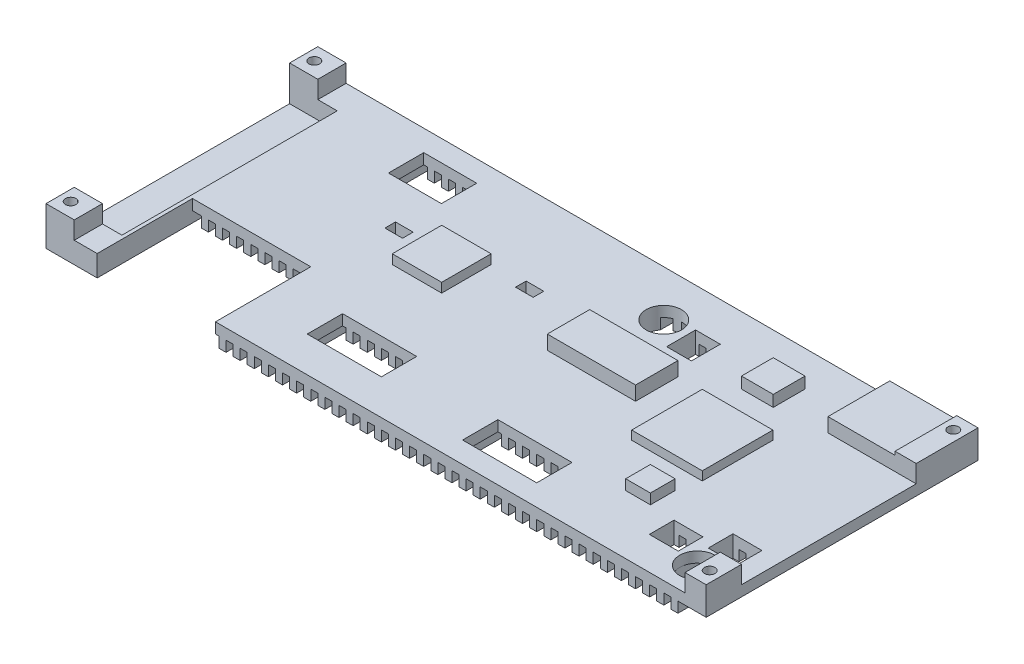
from build123d import *

# Parameters (mm, degrees)
SKETCH_1_W           = 187
SKETCH_1_H           = 77
EXTRUDE_1_DEPTH      = 6
SKETCH_5_R           = 5
SKETCH_5_W           = 21
SKETCH_5_H           = 10
SKETCH_5_W_2         = 15
SKETCH_5_W_3         = 5
SKETCH_5_H_2         = 3
SKETCH_5_W_4         = 33.5
SKETCH_5_H_3         = 27
CUT_EXTRUDE_2_DEPTH  = 7
SKETCH_7_OUTSIDE_W   = 229.464
SKETCH_7_OUTSIDE_H   = 119.464
SKETCH_7_OUTSIDE_W_2 = 2
SKETCH_7_OUTSIDE_H_2 = 77
SKETCH_7_OUTSIDE_H_3 = 50
CUT_EXTRUDE_13_DEPTH = 3
SKETCH_9_W           = 25
SKETCH_9_H           = 17.5
SKETCH_9_H_2         = 12
EXTRUDE_3_DEPTH      = 4
SKETCH_10_W          = 6
SKETCH_10_H          = 17.5
EXTRUDE_7_DEPTH      = 1
SKETCH_16_R          = 1.5
CUT_EXTRUDE_15_DEPTH = 12
SKETCH_17_W          = 6
SKETCH_17_H          = 10
EXTRUDE_8_DEPTH      = 5
SKETCH_18_R          = 1.5
CUT_EXTRUDE_16_DEPTH = 12
SKETCH_20_W          = 20
SKETCH_20_H          = 20
EXTRUDE_9_DEPTH      = 2.5
SKETCH_21_W          = 8.2
SKETCH_21_H          = 7
SKETCH_21_W_2        = 7
SKETCH_21_H_2        = 8.2
CUT_EXTRUDE_17_DEPTH = 7
SKETCH_22_W          = 9
SKETCH_22_H          = 9
EXTRUDE_10_DEPTH     = 3.2
SKETCH_24_W          = 14
SKETCH_24_H          = 14
EXTRUDE_12_DEPTH     = 2.65
SKETCH_23_W          = 7
SKETCH_23_H          = 7
EXTRUDE_11_DEPTH     = 2.9
SKETCH_25_W          = 14.5
SKETCH_25_H          = 77
EXTRUDE_13_DEPTH     = 3
SKETCH_26_W          = 13.5
SKETCH_26_H          = 61
CUT_EXTRUDE_19_DEPTH = 5
SKETCH_27_W          = 8
SKETCH_27_H          = 8
EXTRUDE_14_DEPTH     = 5
SKETCH_28_R          = 1.5
CUT_EXTRUDE_20_DEPTH = 12
SKETCH_29_R          = 1.5
CUT_EXTRUDE_21_DEPTH = 12


with BuildPart() as part:
    # Эскиз1 → Бобышка-Вытянуть1 (new body)
    with BuildSketch(Plane(origin=(0, 0, 0), x_dir=(1, 0, 0), z_dir=(0, 1, 0))):
        with Locations((93.5, 38.5)):
            Rectangle(SKETCH_1_W, SKETCH_1_H)
    extrude(amount=EXTRUDE_1_DEPTH)

    # Эскиз5 → Вырез-Вытянуть2 (cut, through all)
    with BuildSketch(Plane(origin=(0, 6, 0), x_dir=(1, 0, 0), z_dir=(0, 1, 0))):
        with Locations((111, 64)):
            Circle(SKETCH_5_R)
        with Locations((176, 8.5)):
            Circle(SKETCH_5_R)
        with Locations((122.5, 11)):
            Rectangle(SKETCH_5_W, SKETCH_5_H)
        with Locations((43.5, 66)):
            Rectangle(SKETCH_5_W_2, SKETCH_5_H)
        with Locations((74.5, 15)):
            Rectangle(SKETCH_5_W, SKETCH_5_H)
        with Locations((84.5, 52.5)):
            Rectangle(SKETCH_5_W_3, SKETCH_5_H_2)
        with Locations((51.5, 48.5)):
            Rectangle(SKETCH_5_W_3, SKETCH_5_H_2)
        with Locations((31.25, 13.5)):
            Rectangle(SKETCH_5_W_4, SKETCH_5_H_3)
    extrude(amount=-CUT_EXTRUDE_2_DEPTH, mode=Mode.SUBTRACT)

    # Эскиз7 outside → Вырез-Вытянуть13 (cut)
    with BuildSketch(Plane.XZ):
        with Locations((93.5, -38.5)):
            Rectangle(SKETCH_7_OUTSIDE_W, SKETCH_7_OUTSIDE_H)
        with Locations((174, -38.5)):
            Rectangle(SKETCH_7_OUTSIDE_W_2, SKETCH_7_OUTSIDE_H_2, mode=Mode.SUBTRACT)
        with Locations((170, -38.5)):
            Rectangle(SKETCH_7_OUTSIDE_W_2, SKETCH_7_OUTSIDE_H_2, mode=Mode.SUBTRACT)
        with Locations((162, -38.5)):
            Rectangle(SKETCH_7_OUTSIDE_W_2, SKETCH_7_OUTSIDE_H_2, mode=Mode.SUBTRACT)
        with Locations((154, -38.5)):
            Rectangle(SKETCH_7_OUTSIDE_W_2, SKETCH_7_OUTSIDE_H_2, mode=Mode.SUBTRACT)
        with Locations((158, -38.5)):
            Rectangle(SKETCH_7_OUTSIDE_W_2, SKETCH_7_OUTSIDE_H_2, mode=Mode.SUBTRACT)
        with Locations((150, -38.5)):
            Rectangle(SKETCH_7_OUTSIDE_W_2, SKETCH_7_OUTSIDE_H_2, mode=Mode.SUBTRACT)
        with Locations((146, -38.5)):
            Rectangle(SKETCH_7_OUTSIDE_W_2, SKETCH_7_OUTSIDE_H_2, mode=Mode.SUBTRACT)
        with Locations((138, -38.5)):
            Rectangle(SKETCH_7_OUTSIDE_W_2, SKETCH_7_OUTSIDE_H_2, mode=Mode.SUBTRACT)
        with Locations((142, -38.5)):
            Rectangle(SKETCH_7_OUTSIDE_W_2, SKETCH_7_OUTSIDE_H_2, mode=Mode.SUBTRACT)
        with Locations((166, -38.5)):
            Rectangle(SKETCH_7_OUTSIDE_W_2, SKETCH_7_OUTSIDE_H_2, mode=Mode.SUBTRACT)
        with Locations((134, -38.5)):
            Rectangle(SKETCH_7_OUTSIDE_W_2, SKETCH_7_OUTSIDE_H_2, mode=Mode.SUBTRACT)
        with Locations((130, -38.5)):
            Rectangle(SKETCH_7_OUTSIDE_W_2, SKETCH_7_OUTSIDE_H_2, mode=Mode.SUBTRACT)
        with Locations((126, -38.5)):
            Rectangle(SKETCH_7_OUTSIDE_W_2, SKETCH_7_OUTSIDE_H_2, mode=Mode.SUBTRACT)
        with Locations((118, -38.5)):
            Rectangle(SKETCH_7_OUTSIDE_W_2, SKETCH_7_OUTSIDE_H_2, mode=Mode.SUBTRACT)
        with Locations((122, -38.5)):
            Rectangle(SKETCH_7_OUTSIDE_W_2, SKETCH_7_OUTSIDE_H_2, mode=Mode.SUBTRACT)
        with Locations((114, -38.5)):
            Rectangle(SKETCH_7_OUTSIDE_W_2, SKETCH_7_OUTSIDE_H_2, mode=Mode.SUBTRACT)
        with Locations((110, -38.5)):
            Rectangle(SKETCH_7_OUTSIDE_W_2, SKETCH_7_OUTSIDE_H_2, mode=Mode.SUBTRACT)
        with Locations((106, -38.5)):
            Rectangle(SKETCH_7_OUTSIDE_W_2, SKETCH_7_OUTSIDE_H_2, mode=Mode.SUBTRACT)
        with Locations((102, -38.5)):
            Rectangle(SKETCH_7_OUTSIDE_W_2, SKETCH_7_OUTSIDE_H_2, mode=Mode.SUBTRACT)
        with Locations((98, -38.5)):
            Rectangle(SKETCH_7_OUTSIDE_W_2, SKETCH_7_OUTSIDE_H_2, mode=Mode.SUBTRACT)
        with Locations((94, -38.5)):
            Rectangle(SKETCH_7_OUTSIDE_W_2, SKETCH_7_OUTSIDE_H_2, mode=Mode.SUBTRACT)
        with Locations((178, -38.5)):
            Rectangle(SKETCH_7_OUTSIDE_W_2, SKETCH_7_OUTSIDE_H_2, mode=Mode.SUBTRACT)
        with Locations((90, -38.5)):
            Rectangle(SKETCH_7_OUTSIDE_W_2, SKETCH_7_OUTSIDE_H_2, mode=Mode.SUBTRACT)
        with Locations((86, -38.5)):
            Rectangle(SKETCH_7_OUTSIDE_W_2, SKETCH_7_OUTSIDE_H_2, mode=Mode.SUBTRACT)
        with Locations((82, -38.5)):
            Rectangle(SKETCH_7_OUTSIDE_W_2, SKETCH_7_OUTSIDE_H_2, mode=Mode.SUBTRACT)
        with Locations((78, -38.5)):
            Rectangle(SKETCH_7_OUTSIDE_W_2, SKETCH_7_OUTSIDE_H_2, mode=Mode.SUBTRACT)
        with Locations((74, -38.5)):
            Rectangle(SKETCH_7_OUTSIDE_W_2, SKETCH_7_OUTSIDE_H_2, mode=Mode.SUBTRACT)
        with Locations((70, -38.5)):
            Rectangle(SKETCH_7_OUTSIDE_W_2, SKETCH_7_OUTSIDE_H_2, mode=Mode.SUBTRACT)
        with Locations((62, -38.5)):
            Rectangle(SKETCH_7_OUTSIDE_W_2, SKETCH_7_OUTSIDE_H_2, mode=Mode.SUBTRACT)
        with Locations((66, -38.5)):
            Rectangle(SKETCH_7_OUTSIDE_W_2, SKETCH_7_OUTSIDE_H_2, mode=Mode.SUBTRACT)
        with Locations((58, -38.5)):
            Rectangle(SKETCH_7_OUTSIDE_W_2, SKETCH_7_OUTSIDE_H_2, mode=Mode.SUBTRACT)
        with Locations((54, -38.5)):
            Rectangle(SKETCH_7_OUTSIDE_W_2, SKETCH_7_OUTSIDE_H_2, mode=Mode.SUBTRACT)
        with Locations((50, -38.5)):
            Rectangle(SKETCH_7_OUTSIDE_W_2, SKETCH_7_OUTSIDE_H_2, mode=Mode.SUBTRACT)
        with Locations((46, -52)):
            Rectangle(SKETCH_7_OUTSIDE_W_2, SKETCH_7_OUTSIDE_H_3, mode=Mode.SUBTRACT)
        with Locations((42, -52)):
            Rectangle(SKETCH_7_OUTSIDE_W_2, SKETCH_7_OUTSIDE_H_3, mode=Mode.SUBTRACT)
        with Locations((38, -52)):
            Rectangle(SKETCH_7_OUTSIDE_W_2, SKETCH_7_OUTSIDE_H_3, mode=Mode.SUBTRACT)
        with Locations((34, -52)):
            Rectangle(SKETCH_7_OUTSIDE_W_2, SKETCH_7_OUTSIDE_H_3, mode=Mode.SUBTRACT)
        with Locations((30, -52)):
            Rectangle(SKETCH_7_OUTSIDE_W_2, SKETCH_7_OUTSIDE_H_3, mode=Mode.SUBTRACT)
        with Locations((26, -52)):
            Rectangle(SKETCH_7_OUTSIDE_W_2, SKETCH_7_OUTSIDE_H_3, mode=Mode.SUBTRACT)
        with Locations((22, -52)):
            Rectangle(SKETCH_7_OUTSIDE_W_2, SKETCH_7_OUTSIDE_H_3, mode=Mode.SUBTRACT)
        with Locations((18, -52)):
            Rectangle(SKETCH_7_OUTSIDE_W_2, SKETCH_7_OUTSIDE_H_3, mode=Mode.SUBTRACT)
    extrude(amount=-CUT_EXTRUDE_13_DEPTH, mode=Mode.SUBTRACT)

    # Эскиз9 → Бобышка-Вытянуть3 (add)
    with BuildSketch(Plane(origin=(0, 6, 0), x_dir=(1, 0, 0), z_dir=(0, 1, 0))):
        with Locations((174.5, 68.25)):
            Rectangle(SKETCH_9_W, SKETCH_9_H)
        with Locations((114.5, 46)):
            Rectangle(SKETCH_9_W, SKETCH_9_H_2)
    extrude(amount=EXTRUDE_3_DEPTH)

    # Эскиз10 → Бобышка-Вытянуть7 (add)
    with BuildSketch(Plane(origin=(0, 10, 0), x_dir=(1, 0, 0), z_dir=(0, 1, 0))):
        with Locations((184, 68.25)):
            Rectangle(SKETCH_10_W, SKETCH_10_H)
    extrude(amount=EXTRUDE_7_DEPTH)

    # Эскиз16 → Вырез-Вытянуть15 (cut, through all)
    with BuildSketch(Plane(origin=(0, 11, 0), x_dir=(1, 0, 0), z_dir=(0, 1, 0))):
        with Locations((184, 73)):
            Circle(SKETCH_16_R)
    extrude(amount=-CUT_EXTRUDE_15_DEPTH, mode=Mode.SUBTRACT)

    # Эскиз17 → Бобышка-Вытянуть8 (add)
    with BuildSketch(Plane(origin=(0, 6, 0), x_dir=(1, 0, 0), z_dir=(0, 1, 0))):
        with Locations((184, 5)):
            Rectangle(SKETCH_17_W, SKETCH_17_H)
    extrude(amount=EXTRUDE_8_DEPTH)

    # Эскиз18 → Вырез-Вытянуть16 (cut, through all)
    with BuildSketch(Plane(origin=(0, 11, 0), x_dir=(1, 0, 0), z_dir=(0, 1, 0))):
        with Locations((184, 4)):
            Circle(SKETCH_18_R)
    extrude(amount=-CUT_EXTRUDE_16_DEPTH, mode=Mode.SUBTRACT)

    # Эскиз20 → Бобышка-Вытянуть9 (add)
    with BuildSketch(Plane(origin=(0, 6, 0), x_dir=(1, 0, 0), z_dir=(0, 1, 0))):
        with Locations((146, 39.9)):
            Rectangle(SKETCH_20_W, SKETCH_20_H)
    extrude(amount=EXTRUDE_9_DEPTH)

    # Эскиз21 → Вырез-Вытянуть17 (cut, through all)
    with BuildSketch(Plane(origin=(0, 6, 0), x_dir=(1, 0, 0), z_dir=(0, 1, 0))):
        with Locations((177.4, 17.8)):
            Rectangle(SKETCH_21_W, SKETCH_21_H)
        with Locations((165.7, 12.8)):
            Rectangle(SKETCH_21_W, SKETCH_21_H)
        with Locations((121.5, 61.9)):
            Rectangle(SKETCH_21_W_2, SKETCH_21_H_2)
    extrude(amount=-CUT_EXTRUDE_17_DEPTH, mode=Mode.SUBTRACT)

    # Эскиз22 → Бобышка-Вытянуть10 (add)
    with BuildSketch(Plane(origin=(0, 6, 0), x_dir=(1, 0, 0), z_dir=(0, 1, 0))):
        with Locations((143.5, 62.5)):
            Rectangle(SKETCH_22_W, SKETCH_22_H)
    extrude(amount=EXTRUDE_10_DEPTH)

    # Эскиз24 → Бобышка-Вытянуть12 (add)
    with BuildSketch(Plane(origin=(0, 6, 0), x_dir=(1, 0, 0), z_dir=(0, 1, 0))):
        with Locations((66, 46.083478514)):
            Rectangle(SKETCH_24_W, SKETCH_24_H)
    extrude(amount=EXTRUDE_12_DEPTH)

    # Эскиз23 → Бобышка-Вытянуть11 (add)
    with BuildSketch(Plane(origin=(0, 6, 0), x_dir=(1, 0, 0), z_dir=(0, 1, 0))):
        with Locations((151, 20.2)):
            Rectangle(SKETCH_23_W, SKETCH_23_H)
    extrude(amount=EXTRUDE_11_DEPTH)

    # Эскиз25 → Бобышка-Вытянуть13 (add)
    with BuildSketch(Plane.XZ.offset(-3)):
        with Locations((7.25, -38.5)):
            Rectangle(SKETCH_25_W, SKETCH_25_H)
    extrude(amount=EXTRUDE_13_DEPTH)

    # Эскиз26 → Вырез-Вытянуть19 (cut)
    with BuildSketch(Plane(origin=(0, 6, 0), x_dir=(1, 0, 0), z_dir=(0, 1, 0))):
        with Locations((6.75, 38.5)):
            Rectangle(SKETCH_26_W, SKETCH_26_H)
    extrude(amount=-CUT_EXTRUDE_19_DEPTH, mode=Mode.SUBTRACT)

    # Эскиз27 → Бобышка-Вытянуть14 (add)
    with BuildSketch(Plane(origin=(0, 6, 0), x_dir=(1, 0, 0), z_dir=(0, 1, 0))):
        with Locations((4, 4)):
            Rectangle(SKETCH_27_W, SKETCH_27_H)
        with Locations((4, 73)):
            Rectangle(SKETCH_27_W, SKETCH_27_H)
    extrude(amount=EXTRUDE_14_DEPTH)

    # Эскиз28 → Вырез-Вытянуть20 (cut, through all)
    with BuildSketch(Plane(origin=(0, 11, 0), x_dir=(1, 0, 0), z_dir=(0, 1, 0))):
        with Locations((3, 4)):
            Circle(SKETCH_28_R)
    extrude(amount=-CUT_EXTRUDE_20_DEPTH, mode=Mode.SUBTRACT)

    # Эскиз29 → Вырез-Вытянуть21 (cut, through all)
    with BuildSketch(Plane(origin=(0, 11, 0), x_dir=(1, 0, 0), z_dir=(0, 1, 0))):
        with Locations((3, 73)):
            Circle(SKETCH_29_R)
    extrude(amount=-CUT_EXTRUDE_21_DEPTH, mode=Mode.SUBTRACT)


solid = part.part
